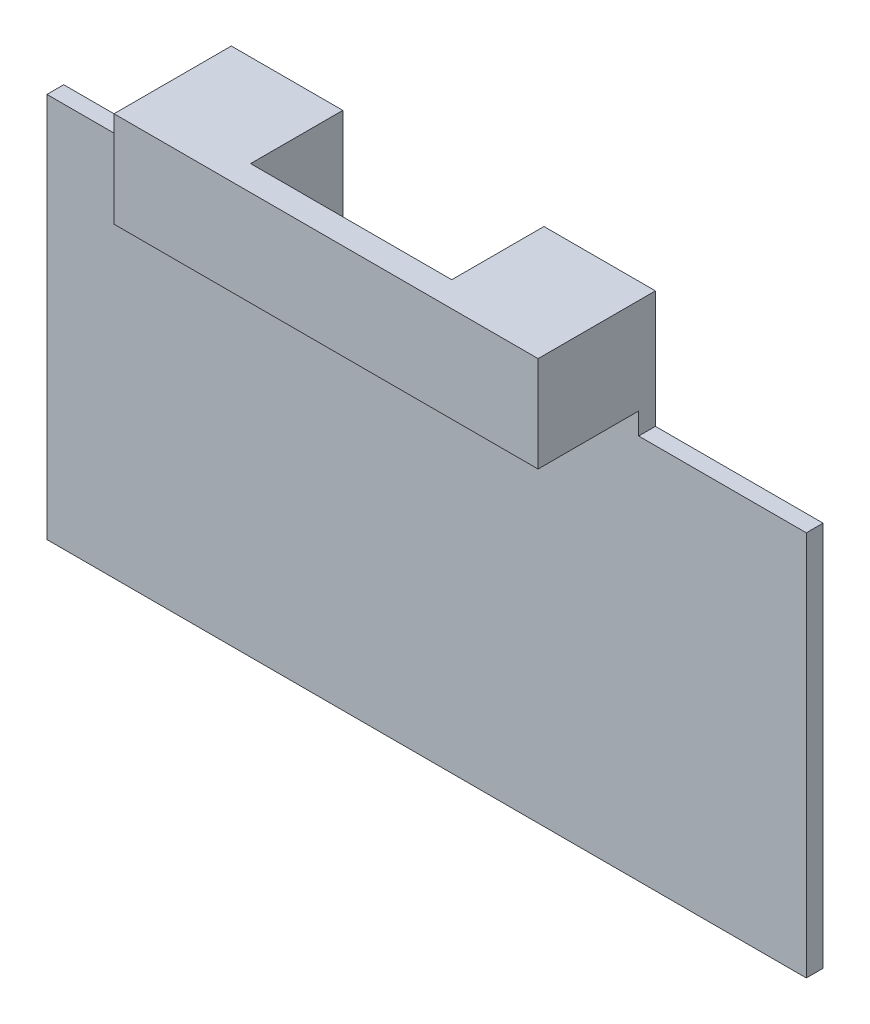
from build123d import *

# Parameters (mm, degrees)
SKETCH1_W           = 45.3
SKETCH1_H           = 30
BOSS_EXTRUDE1_DEPTH = 7
SKETCH2_W           = 45.3
SKETCH2_H           = 24.294385672
CUT_EXTRUDE1_DEPTH  = 6
SKETCH5_W           = 12
SKETCH5_H           = 5.5
SKETCH5_W_2         = 10
SKETCH5_H_2         = 7
CUT_EXTRUDE2_DEPTH  = 7


with BuildPart() as part:
    # Sketch1 → Boss-Extrude1 (new body)
    with BuildSketch(Plane.XY):
        with Locations((5.590822785, 11.37721519)):
            Rectangle(SKETCH1_W, SKETCH1_H)
    extrude(amount=BOSS_EXTRUDE1_DEPTH)

    # Sketch2 → Cut-Extrude1 (cut)
    with BuildSketch(Plane.XY.offset(7)):
        with Locations((5.590822785, 8.524408026)):
            Rectangle(SKETCH2_W, SKETCH2_H)
    extrude(amount=-CUT_EXTRUDE1_DEPTH, mode=Mode.SUBTRACT)

    # Sketch5 → Cut-Extrude2 (cut)
    with BuildSketch(Plane(origin=(0, 26.37721519, 0), x_dir=(1, 0, 0), z_dir=(0, 1, 0))):
        with Locations((5.590822785, -2.75)):
            Rectangle(SKETCH5_W, SKETCH5_H)
        with Locations((-12.059177215, -3.5)):
            Rectangle(SKETCH5_W_2, SKETCH5_H_2)
        with Locations((23.240822785, -3.5)):
            Rectangle(SKETCH5_W_2, SKETCH5_H_2)
    extrude(amount=-CUT_EXTRUDE2_DEPTH, mode=Mode.SUBTRACT)


solid = part.part
